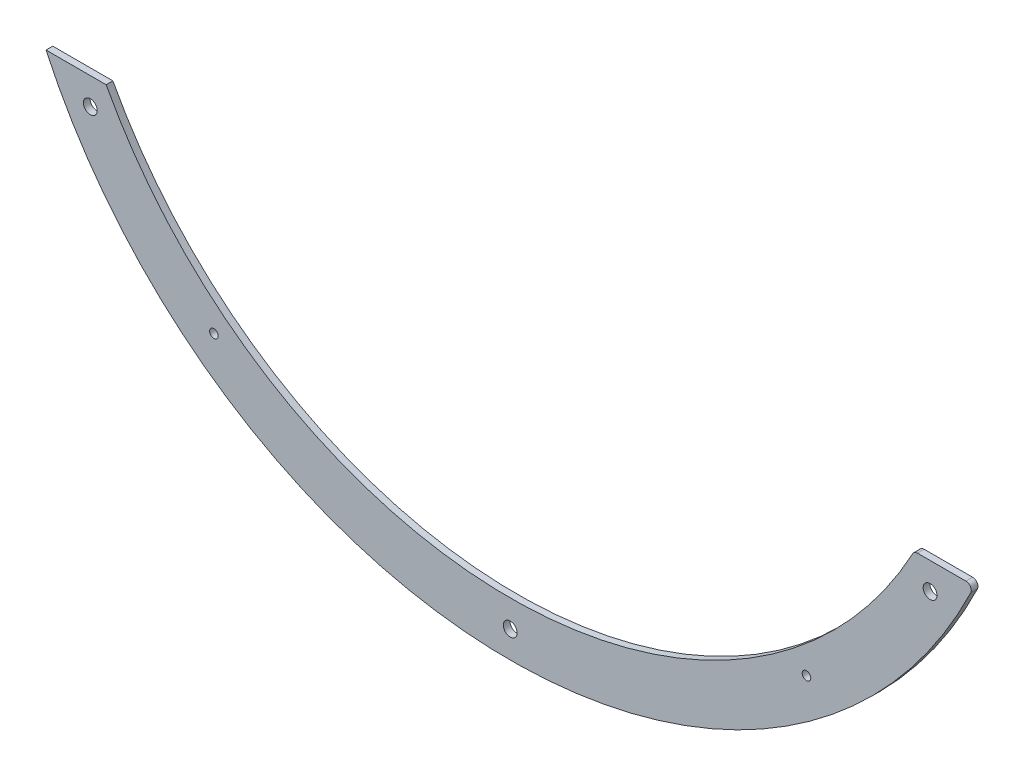
from build123d import *

# Parameters (mm, degrees)
SKETCH1_R           = 2.0193
SKETCH1_R_2         = 3.2639
BOSS_EXTRUDE1_DEPTH = 3.175
FILLET1_R           = 2.54


with BuildPart() as part:
    # Sketch1 → Boss-Extrude1 (new body)
    with BuildSketch(Plane.XY):
        with BuildLine():
            Line((-190.5, -101.6), (-218.867836833, -101.6))
            ThreePointArc((-218.867836833, -101.6), (0, -241.3), (218.867836833, -101.6))
            Line((218.867836833, -101.6), (190.5, -101.6))
            ThreePointArc((190.5, -101.6), (0, -215.9), (-190.5, -101.6))
        make_face()
        with Locations((-139.7, -177.8)):
            Circle(SKETCH1_R, mode=Mode.SUBTRACT)
        with Locations((-197.973407305, -114.3)):
            Circle(SKETCH1_R_2, mode=Mode.SUBTRACT)
        with Locations((0, -228.6)):
            Circle(SKETCH1_R_2, mode=Mode.SUBTRACT)
        with Locations((139.7, -177.8)):
            Circle(SKETCH1_R, mode=Mode.SUBTRACT)
        with Locations((197.973407305, -114.3)):
            Circle(SKETCH1_R_2, mode=Mode.SUBTRACT)
    extrude(amount=BOSS_EXTRUDE1_DEPTH)

    # Fillet1
    fillet1_edges = [part.edges().sort_by_distance(p)[0] for p in [
        (190.5, -101.6, 1.5875),
        (218.867836833, -101.6, 1.5875),
    ]]
    fillet(fillet1_edges, radius=FILLET1_R)


solid = part.part
